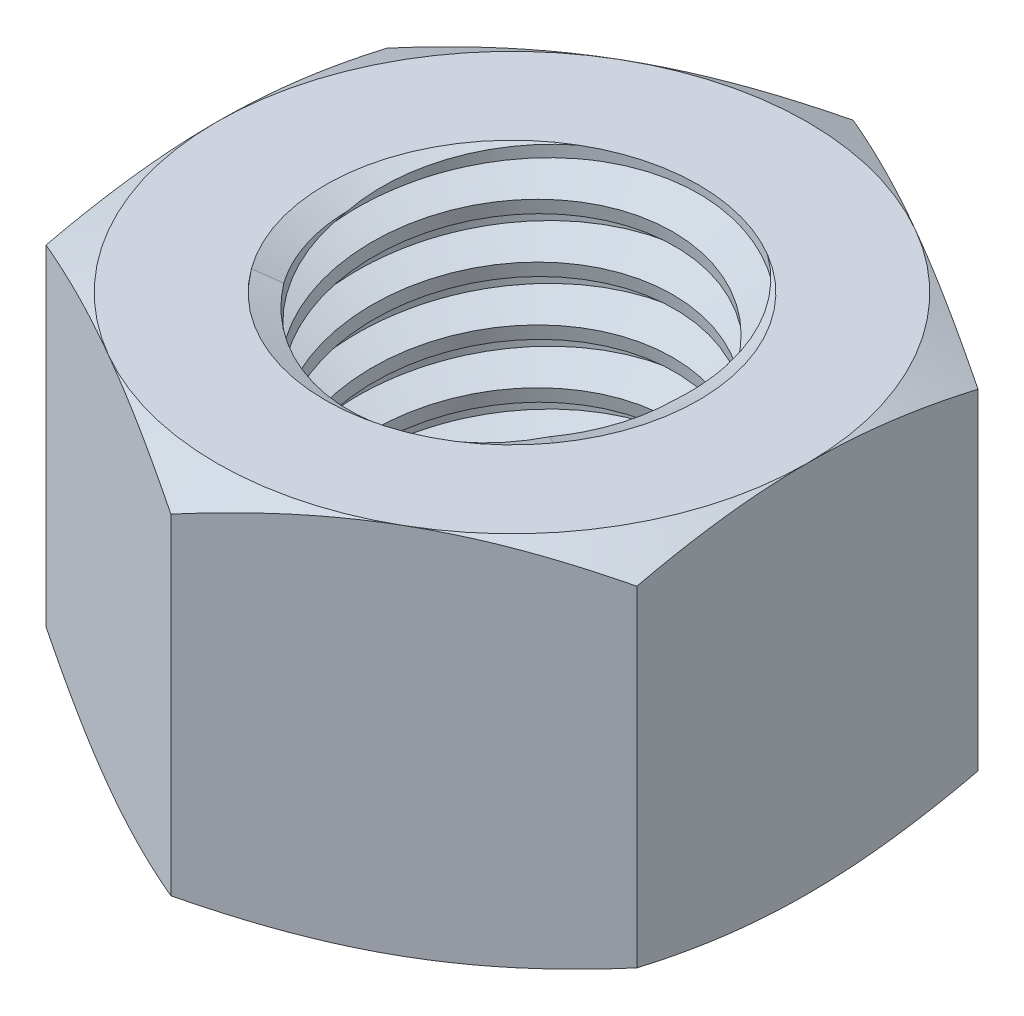
from build123d import *

# Parameters (mm, degrees)
EXTRUDE1_DEPTH       = 6
SKETCH2_W            = 6
SKETCH2_H            = 12
LPATTERN1_COUNT      = 7
LPATTERN1_PITCH      = 1.75
LPATTERN1_COUNT_DIR2 = 2
LPATTERN1_PITCH_DIR2 = 1.75


with BuildPart() as part:
    # Sketch1 → Extrude1 (new, symmetric)
    with BuildSketch(Plane(origin=(0, 0, 0), x_dir=(1, 0, 0), z_dir=(0, 1, 0))):
        Polygon((0, 10.969655115), (-9.5, 5.484827557), (-9.5, -5.484827557), (0, -10.969655115), (9.5, -5.484827557), (9.5, 5.484827557), align=None)
    extrude(amount=EXTRUDE1_DEPTH, both=True)

    # Sketch4 → Cut-Revolve2 (revolve, cut)
    with BuildSketch(Plane(origin=(0, 0, 0), x_dir=(0, 0, -1), z_dir=(1, 0, 0))):
        Polygon((0, 6), (6, 6), (5.1731842, 5.614449461), (5.1731842, -5.614449461), (6, -6), (0, -6), align=None)
    revolve(axis=Axis((0, 6, 0), (0, 1, 0)), mode=Mode.SUBTRACT)


with BuildPart() as body_2:
    # Sketch2 → Revolve1 (revolve)
    with BuildSketch(Plane(origin=(0, 0, 0), x_dir=(0, 0, -1), z_dir=(1, 0, 0))):
        with Locations((3, 0)):
            Rectangle(SKETCH2_W, SKETCH2_H)
    revolve(axis=Axis((0, -12, 0), (0, 1, 0)))

    # Sketch3 → Cut-Revolve1 (revolve, cut)
    with BuildSketch(Plane(origin=(0, 0, 0), x_dir=(0, 0, -1), z_dir=(1, 0, 0))):
        Polygon((6.031567133, 5.78353966), (6.252537063, 4.268317283), (5.236318466, 4.672778437), (5.1731842, 5.105699116), align=None)
    cut_revolve1 = revolve(axis=Axis((0, 6, 0.272677338), (0, -0.9895329810632816, -0.14430689307172867)), mode=Mode.SUBTRACT)

    # LPattern1: Cut-Revolve1 7 × 2
    with Locations(*[Vector(0, -1, 0) * (i * LPATTERN1_PITCH) + Vector(0, 1, 0) * (j * LPATTERN1_PITCH_DIR2) for i in range(LPATTERN1_COUNT) for j in range(LPATTERN1_COUNT_DIR2) if (i, j) != (0, 0)]):
        add(cut_revolve1, mode=Mode.SUBTRACT)


with BuildPart() as part_1:
    add(part.part)

    # Combine1: cut body 2
    add(body_2.part, mode=Mode.SUBTRACT)

    # Sketch5 → Cut-Revolve3 (revolve, cut)
    with BuildSketch(Plane(origin=(0, 0, 0), x_dir=(0, 0, -1), z_dir=(1, 0, 0))):
        Polygon((0, -6), (9.5, -6), (10.969655115, -5.314688565), (10.969655115, 5.314688565), (9.5, 6), (0, 6), (0, 7.27), (12.239655115, 7.27), (12.239655115, -7.27), (0, -7.27), align=None)
    revolve(axis=Axis((0, -6, 0), (0, 1, 0)), mode=Mode.SUBTRACT)


solid = part_1.part
